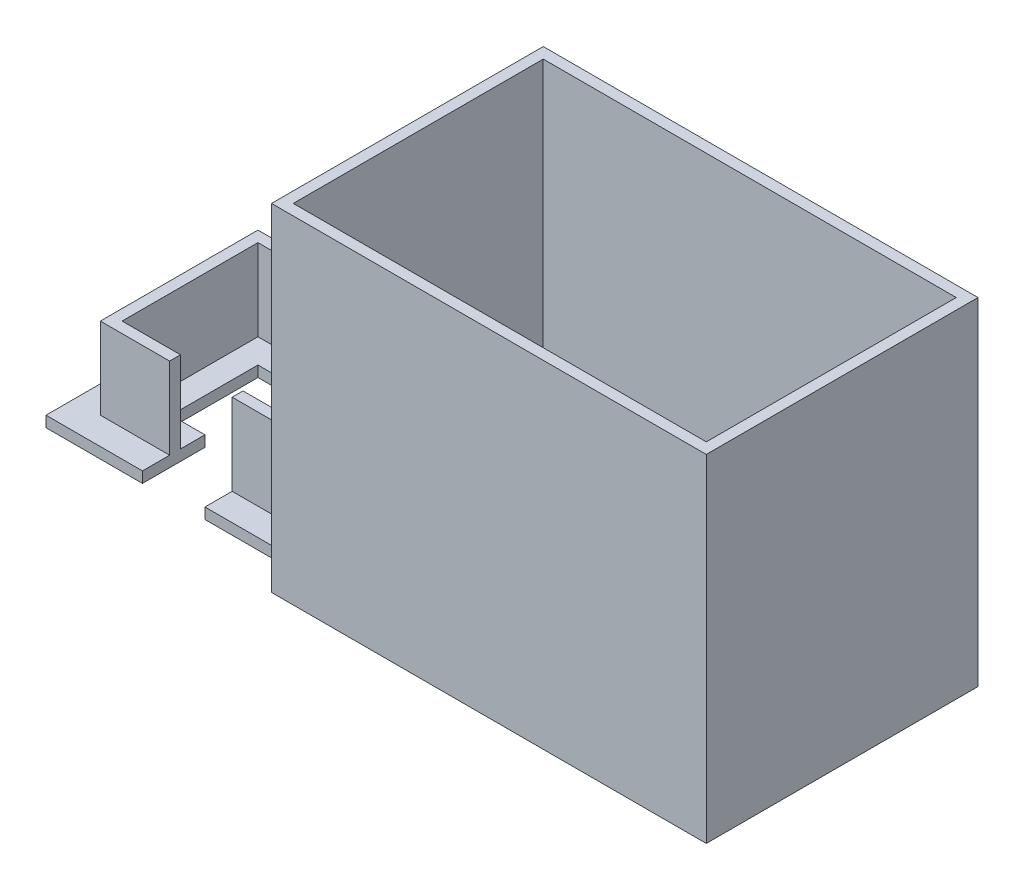
from build123d import *

# Parameters (mm, degrees)
BOSS_EXTRUDE1_DEPTH = 78.74
SHELL3_T            = -2.54
SKETCH1_3_W         = 59.69
SKETCH1_3_H         = 49.53
BOSS_EXTRUDE2_DEPTH = 2.54
BOSS_EXTRUDE3_DEPTH = 19.05
SKETCH3_W           = 45.085
SKETCH3_H           = 20.32
CUT_EXTRUDE1_DEPTH  = 3.54
SKETCH4_W           = 14.605
SKETCH4_H           = 14.605
CUT_EXTRUDE2_DEPTH  = 22.59


with BuildPart() as part:
    # Sketch1 → Boss-Extrude1 (new body)
    with BuildSketch(Plane(origin=(0, 0, 0), x_dir=(1, 0, 0), z_dir=(0, 1, 0))):
        Polygon((-50.8, 24.765), (-50.8, -24.765), (-50.8, -31.75), (50.8, -31.75), (50.8, 31.75), (-50.8, 31.75), align=None)
    extrude(amount=BOSS_EXTRUDE1_DEPTH)

    # Shell3
    shell3_openings = [part.faces().sort_by_distance(p)[0] for p in [
        (0, 78.74, 0),
    ]]
    offset(amount=SHELL3_T, openings=shell3_openings, kind=Kind.INTERSECTION)

    # Sketch1_3 → Boss-Extrude2 (add)
    with BuildSketch(Plane(origin=(0, 0, 0), x_dir=(1, 0, 0), z_dir=(0, 1, 0))):
        with Locations((-80.645, 0)):
            Rectangle(SKETCH1_3_W, SKETCH1_3_H)
    extrude(amount=BOSS_EXTRUDE2_DEPTH)

    # Sketch2 → Boss-Extrude3 (add)
    with BuildSketch(Plane(origin=(0, 2.54, 0), x_dir=(1, 0, 0), z_dir=(0, 1, 0))):
        Polygon((-50.8, 15.875), (-50.8, 18.415), (-104.14, 18.415), (-104.14, -18.415), (-50.8, -18.415), (-50.8, -15.875), (-101.6, -15.875), (-101.6, 15.875), align=None)
    extrude(amount=BOSS_EXTRUDE3_DEPTH)

    # Sketch3 → Cut-Extrude1 (cut, through all)
    with BuildSketch(Plane(origin=(0, 2.54, 0), x_dir=(1, 0, 0), z_dir=(0, 1, 0))):
        with Locations((-73.3425, 0)):
            Rectangle(SKETCH3_W, SKETCH3_H)
    extrude(amount=-CUT_EXTRUDE1_DEPTH, mode=Mode.SUBTRACT)

    # Sketch4 → Cut-Extrude2 (cut, through all)
    with BuildSketch(Plane(origin=(0, 21.59, 0), x_dir=(1, 0, 0), z_dir=(0, 1, 0))):
        with Locations((-80.645, -17.4625)):
            Rectangle(SKETCH4_W, SKETCH4_H)
    extrude(amount=-CUT_EXTRUDE2_DEPTH, mode=Mode.SUBTRACT)


solid = part.part
